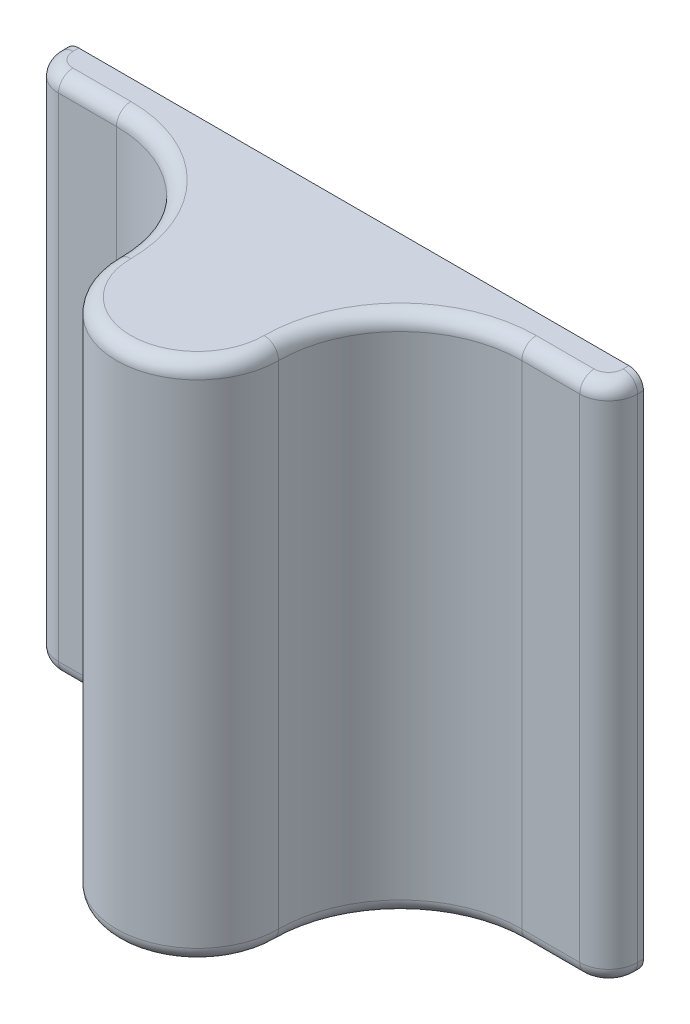
from build123d import *

# Parameters (mm, degrees)
BOSS_EXTRUDE2_DEPTH = 9
FILLET1_R           = 0.5
CUT_EXTRUDE1_START  = -5.4
CUT_EXTRUDE1_DEPTH  = 5.4


with BuildPart() as part:
    # Sketch3 → Boss-Extrude2 (new body, symmetric)
    with BuildSketch(Plane(origin=(0, 0, 0), x_dir=(-1, 0, 0), z_dir=(0, -1, 0))):
        with BuildLine():
            Line((-12.669323516, -16.6), (-2.669323516, -16.6))
            Line((-2.669323516, -16.6), (-2.669323516, -16.8))
            ThreePointArc((-2.669323516, -16.8), (-2.962216735, -17.507106781), (-3.669323516, -17.8))
            Line((-3.669323516, -17.8), (-5.669323516, -17.8))
            ThreePointArc((-5.669323516, -17.8), (-8.639171997, -19.030151519), (-9.869323516, -22))
            ThreePointArc((-9.869323516, -22), (-12.669323516, -24.8), (-15.469323516, -22))
            ThreePointArc((-15.469323516, -22), (-16.699475035, -19.030151519), (-19.669323516, -17.8))
            Line((-19.669323516, -17.8), (-21.669323516, -17.8))
            ThreePointArc((-21.669323516, -17.8), (-22.376430297, -17.507106781), (-22.669323516, -16.8))
            Line((-22.669323516, -16.8), (-22.669323516, -16.6))
            Line((-22.669323516, -16.6), (-12.669323516, -16.6))
        make_face()
    extrude(amount=BOSS_EXTRUDE2_DEPTH, both=True)

    # Fillet1
    fillet1_edges = [part.edges().sort_by_distance(p)[0] for p in [
        (22.376430297, -9, 17.507106781),
        (2.669323516, 9, 16.7),
        (2.962216735, 9, 17.507106781),
        (4.669323516, 9, 17.8),
        (8.639171997, 9, 19.030151519),
        (12.669323516, 9, 24.8),
        (16.699475035, 9, 19.030151519),
        (20.669323516, 9, 17.8),
        (20.669323516, -9, 17.8),
        (22.376430297, 9, 17.507106781),
        (22.669323516, 9, 16.7),
        (16.699475035, -9, 19.030151519),
        (12.669323516, -9, 24.8),
        (8.639171997, -9, 19.030151519),
        (4.669323516, -9, 17.8),
        (2.962216735, -9, 17.507106781),
        (2.669323516, -9, 16.7),
        (22.669323516, -9, 16.7),
    ]]
    fillet(fillet1_edges, radius=FILLET1_R)

    # Sketch4 → Cut-Extrude1 (cut)
    with BuildSketch(Plane(origin=(0, 0, 16.6), x_dir=(-1, 0, 0), z_dir=(0, 0, -1)).offset(CUT_EXTRUDE1_START)):
        with BuildLine():
            Line((-14.869323516, 0.8), (-14.869323516, -0.8))
            Line((-14.869323516, -0.8), (-14.769323516, -0.8))
            ThreePointArc((-14.769323516, -0.8), (-14.369323516, -0.6), (-13.969323516, -0.8))
            Line((-13.969323516, -0.8), (-11.369323516, -0.8))
            ThreePointArc((-11.369323516, -0.8), (-10.969323516, -0.6), (-10.569323516, -0.8))
            Line((-10.569323516, -0.8), (-10.469323516, -0.8))
            Line((-10.469323516, -0.8), (-10.469323516, 0.8))
            Line((-10.469323516, 0.8), (-10.569323516, 0.8))
            ThreePointArc((-10.569323516, 0.8), (-10.969323516, 0.6), (-11.369323516, 0.8))
            Line((-11.369323516, 0.8), (-13.969323516, 0.8))
            ThreePointArc((-13.969323516, 0.8), (-14.369323516, 0.6), (-14.769323516, 0.8))
            Line((-14.769323516, 0.8), (-14.869323516, 0.8))
        make_face()
    extrude(amount=CUT_EXTRUDE1_DEPTH, mode=Mode.SUBTRACT)


solid = part.part
